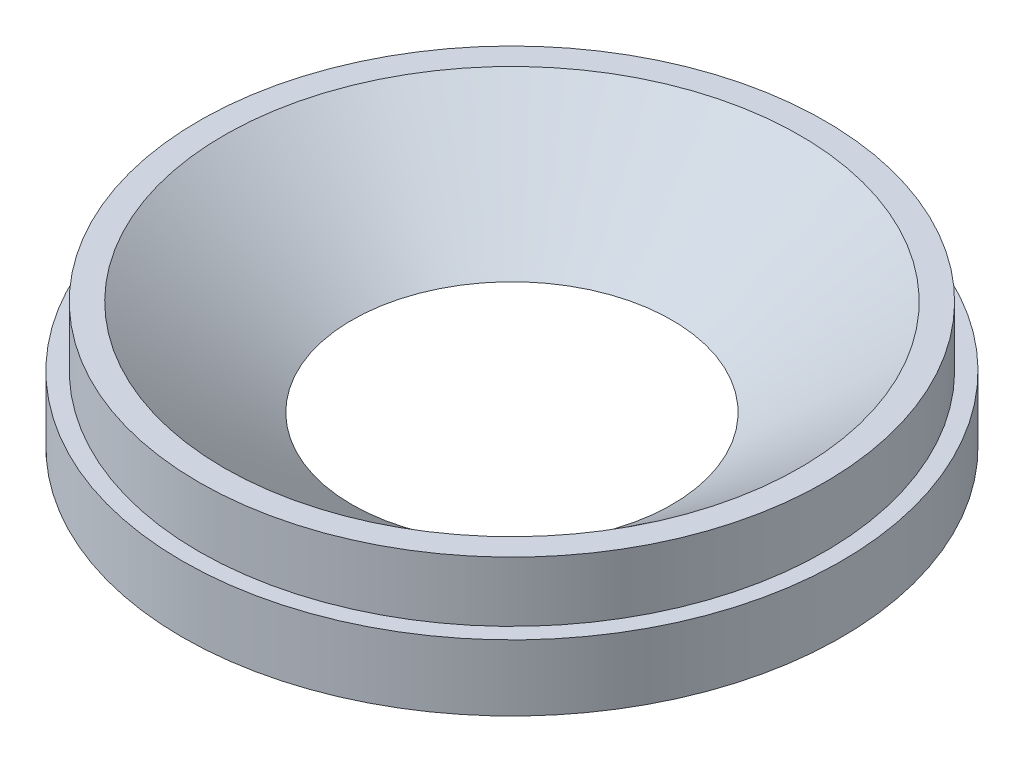
from build123d import *


with BuildPart() as part:
    # Sketch1 → Revolve1 (revolve)
    with BuildSketch(Plane.XY):
        Polygon((-16.937852679, 0), (-30.494324884, 10.16), (-33.147, 10.16), (-33.147, 3.81), (-34.8996, 3.81), (-34.8996, -3.175), (-25.4, -3.175), (-25.4, 0), align=None)
    revolve(axis=Axis((0, 28.5740475, 0), (0, -1, 0)))


solid = part.part
